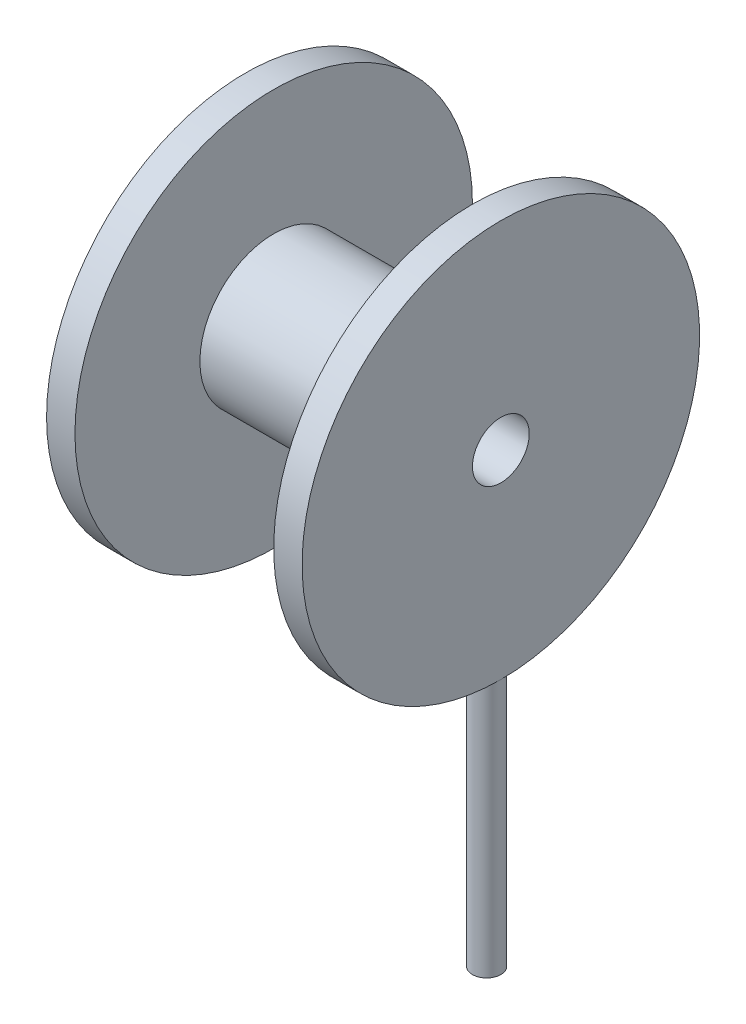
from build123d import *

# Parameters (mm, degrees)
SKIZZE3_W = 2.5
SKIZZE3_H = 50


with BuildPart() as part:
    # Skizze1 → Rotation1 (revolve)
    with BuildSketch(Plane.XY, mode=Mode.PRIVATE) as rotation1_sk:
        Polygon((0, 5), (0, 35), (5, 35), (5, 13), (40, 13), (40, 35), (45, 35), (45, 5), align=None)
    revolve(rotation1_sk.sketch.rotate(Axis((-22.629795441, 0, 0), (1, 0, 0)), 90), axis=Axis((-22.629795441, 0, 0), (1, 0, 0)))  # turned: the seam where the file's is

    # Skizze3 → Rotation2 (revolve)
    with BuildSketch(Plane(origin=(42.5, 0, 0), x_dir=(0, 0, -1), z_dir=(1, 0, 0)), mode=Mode.PRIVATE) as rotation2_sk:
        with Locations((1.25, -55)):
            Rectangle(SKIZZE3_W, SKIZZE3_H)
    revolve(rotation2_sk.sketch.rotate(Axis((42.5, -30, 0), (0, -1, 0)), 180), axis=Axis((42.5, -30, 0), (0, -1, 0)))  # turned: the seam where the file's is


solid = part.part
